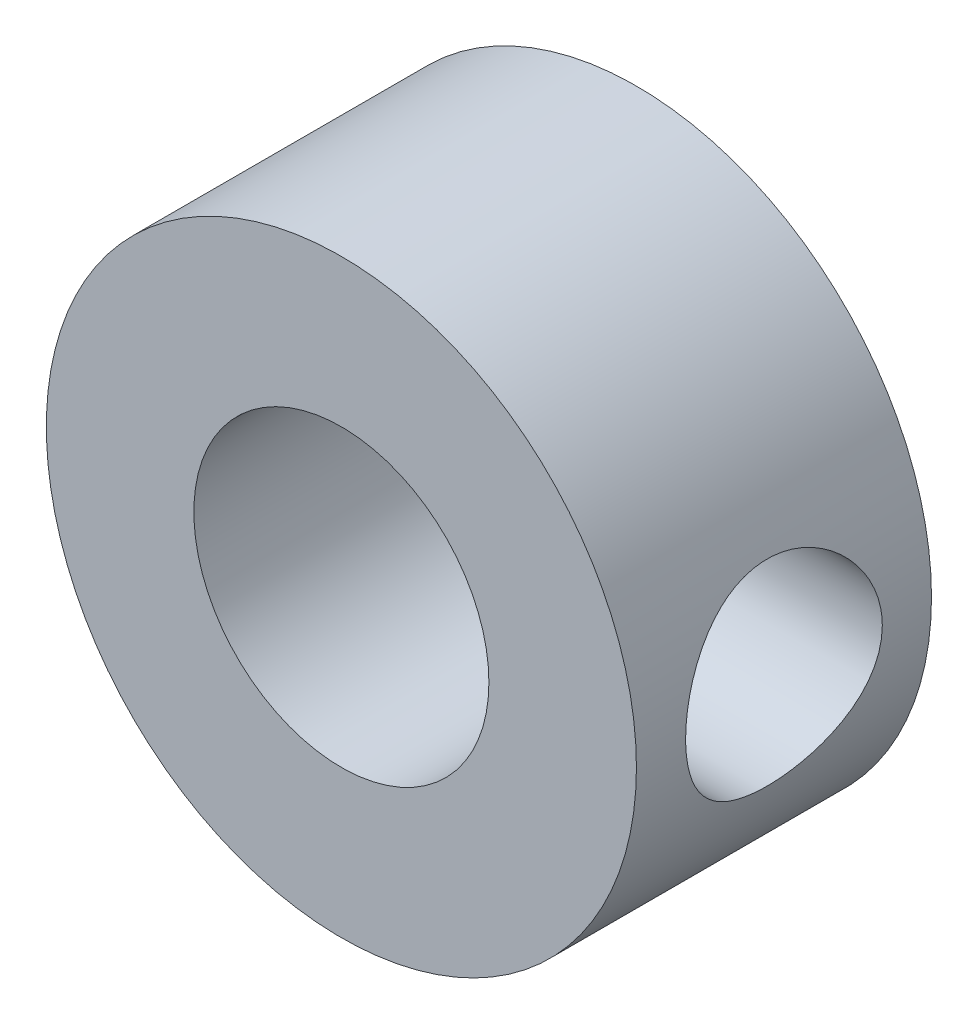
from build123d import *

# Parameters (mm, degrees)
SKETCH1_R          = 9.525
SKETCH1_R_2        = 4.7625
EXTRUDE1_DEPTH     = 4.7625
SKETCH2_R          = 3.175
CUT_EXTRUDE1_DEPTH = 354.553259537


with BuildPart() as part:
    # Sketch1 → Extrude1 (new body, symmetric)
    with BuildSketch(Plane.XY):
        with Locations((-356.05, 162.7)):
            Circle(SKETCH1_R)
        with Locations((-356.05, 162.7)):
            Circle(SKETCH1_R_2, mode=Mode.SUBTRACT)
    extrude(amount=EXTRUDE1_DEPTH, both=True)

    # Sketch2 → Cut-Extrude1 (cut)
    with BuildSketch(Plane(origin=(0, 0, 0), x_dir=(0, 0, -1), z_dir=(1, 0, 0))):
        with Locations((0, 162.7)):
            Circle(SKETCH2_R)
    extrude(amount=-CUT_EXTRUDE1_DEPTH, mode=Mode.SUBTRACT)


solid = part.part
